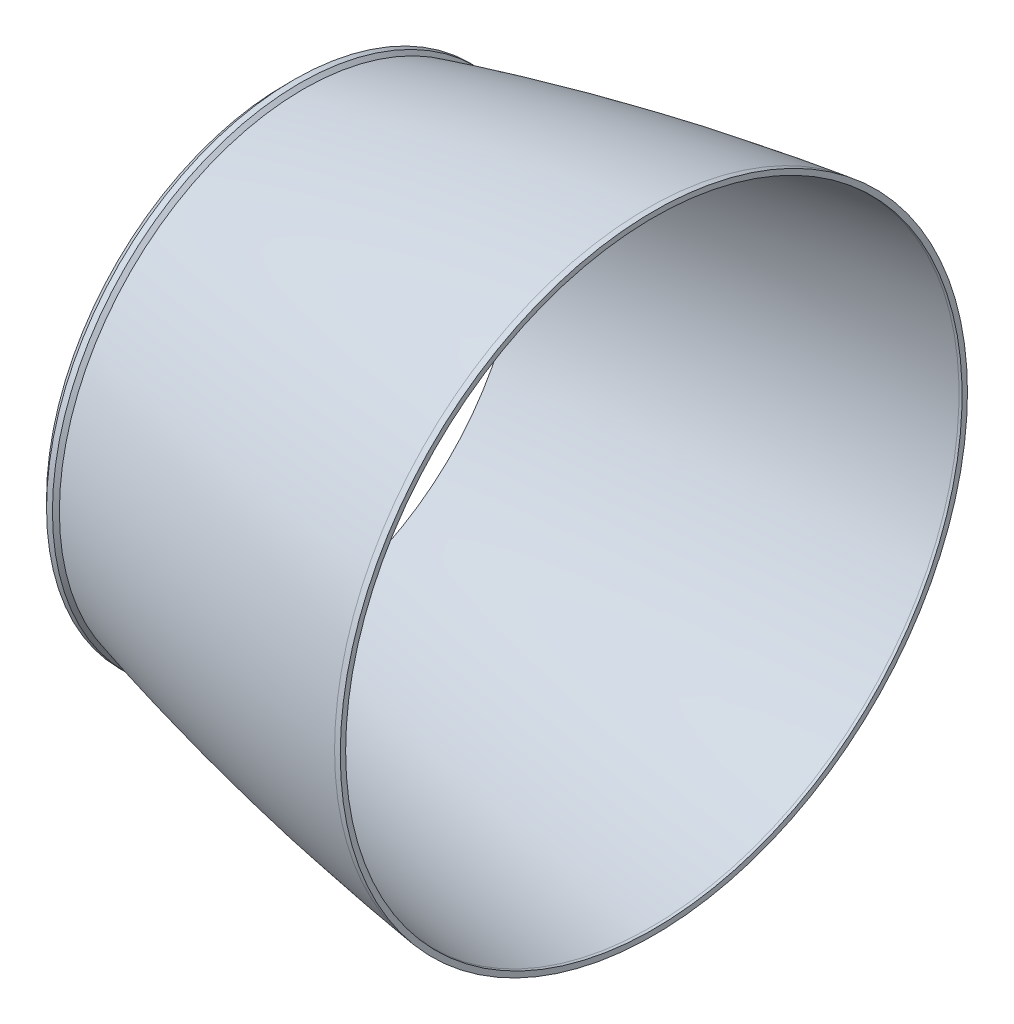
from build123d import *


with BuildPart() as part:
    # Эскиз3 → Повернуть2 (revolve)
    with BuildSketch(Plane(origin=(0, 0, 0), x_dir=(1, 0, 0), z_dir=(0, 1, 0))):
        with BuildLine():
            add(Edge.make_bspline(
                [(379.353962928, 198.000736271), (404.4328048, 204.994009283), (455.184428605, 218.190641399), (532.246171137, 235.349369032), (597.401499005, 247.451639798), (649.887898936, 255.772846045), (676.285219324, 259.484291914), (689.488161006, 261.223219958)],
                knots=[0.55967775, 0.55967775, 0.55967775, 0.55967775, 0.667303278, 0.776467745, 0.885632212, 0.940214445, 0.994796678, 0.994796678, 0.994796678, 0.994796678], degree=3))
            Line((689.488161006, 261.223219958), (691.793962928, 261.52696028))
            Line((691.793962928, 261.52696028), (691.793962928, 266.090063907))
            Line((691.793962928, 266.090063907), (686.793962928, 265.428374509))
            Line((686.793962928, 265.428374509), (686.232087532, 265.354017111))
            add(Edge.make_bspline(
                [(670.259989563, 263.183068918), (675.581810163, 263.92550394), (680.906587628, 264.649251746), (686.232087532, 265.354017111)],
                knots=[0.970871909, 0.970871909, 0.970871909, 0.970871909, 0.992862625, 0.992862625, 0.992862625, 0.992862625], degree=3))
            add(Edge.make_bspline(
                [(394.353962928, 206.971642396), (413.646852853, 212.184810014), (458.514568942, 223.663140269), (529.499752186, 239.486487566), (594.445991087, 251.576272303), (641.469094004, 259.055755248), (662.431248834, 262.090899203), (670.259989563, 263.183068918)],
                knots=[0.584313093, 0.584313093, 0.584313093, 0.584313093, 0.666819765, 0.775500718, 0.884181672, 0.938522149, 0.970871909, 0.970871909, 0.970871909, 0.970871909], degree=3))
            Line((394.353962928, 206.971642396), (394.208149979, 204.347999686))
            Line((394.208149979, 204.347999686), (386.936380559, 202.378250158))
            Line((386.936380559, 202.378250158), (379.353962928, 202.862232348))
            Line((379.353962928, 202.862232348), (379.353962928, 198.000736271))
        make_face()
        with BuildLine():
            Line((386.353962928, 209.862232348), (379.353962928, 202.862232348))
            add(Edge.make_bspline(
                [(379.353962928, 202.862232348), (384.349308427, 204.249522462), (389.349290882, 205.619320667), (394.353962928, 206.971642396)],
                knots=[0.56291045, 0.56291045, 0.56291045, 0.56291045, 0.584313093, 0.584313093, 0.584313093, 0.584313093], degree=3))
            Line((394.353962928, 206.971642396), (391.353962928, 209.862232348))
            Line((391.353962928, 209.862232348), (386.353962928, 209.862232348))
        make_face()
        with BuildLine():
            add(Edge.make_bspline(
                [(379.353962928, 202.862232348), (384.349308427, 204.249522462), (389.349290882, 205.619320667), (394.353962928, 206.971642396)],
                knots=[0.56291045, 0.56291045, 0.56291045, 0.56291045, 0.584313093, 0.584313093, 0.584313093, 0.584313093], degree=3))
            Line((379.353962928, 202.862232348), (386.936380559, 202.378250158))
            Line((386.936380559, 202.378250158), (394.208149979, 204.347999686))
            Line((394.208149979, 204.347999686), (394.353962928, 206.971642396))
        make_face()
    revolve(axis=Axis((0, 0, 0), (1, 0, 0)))


solid = part.part
